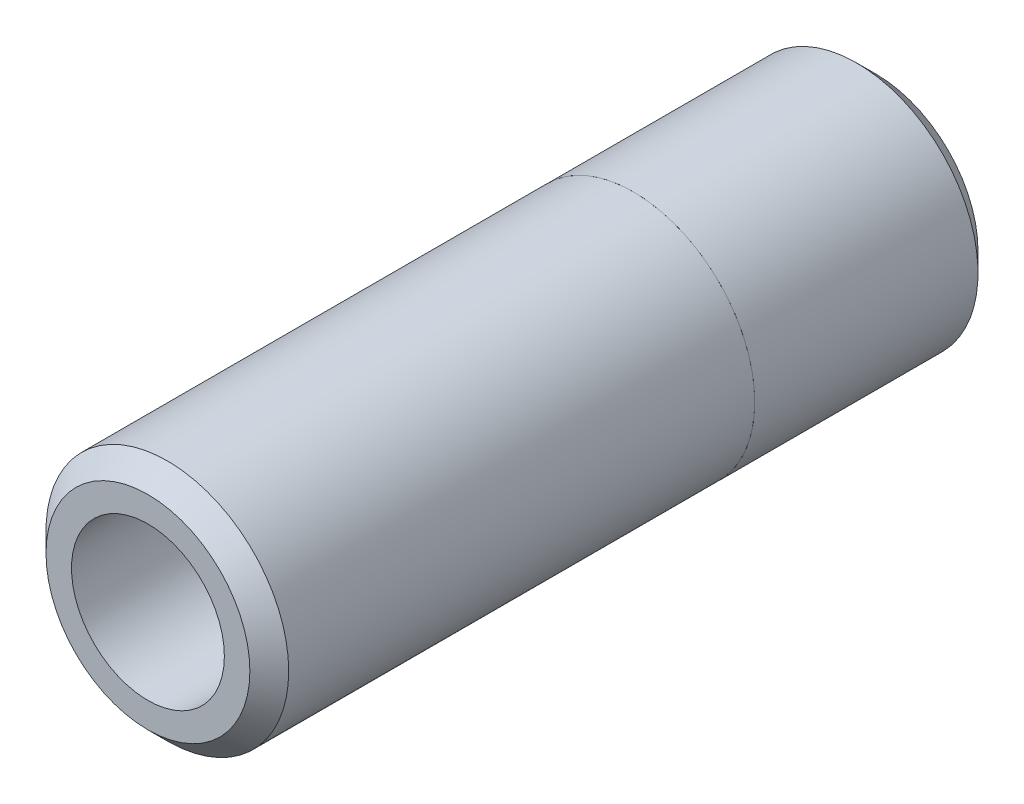
from build123d import *

# Parameters (mm, degrees)
SKETCH1_R               = 4.7625
SIDE_WITH_HOLE_DEPTH    = 19.05
SKETCH2_R               = 4.7625
SIDE_WITHOUT_HOLE_DEPTH = 9.525
CHAMFER1_SIZE           = 0.762
CHAMFER2_SIZE           = 0.762


with BuildPart() as part:
    # Sketch1 → Side With Hole (new body)
    with BuildSketch(Plane.XY):
        Circle(SKETCH1_R)
    extrude(amount=SIDE_WITH_HOLE_DEPTH)


with BuildPart() as body_2:
    # Sketch2 → Side Without Hole (new body)
    with BuildSketch(Plane(origin=(0, 0, 0), x_dir=(-1, 0, 0), z_dir=(0, 0, -1))):
        Circle(SKETCH2_R)
    extrude(amount=SIDE_WITHOUT_HOLE_DEPTH)


with BuildPart() as f_6_0_6_diameter_hole1_tool:
    # Sketch4 → Ø6.0 (6) Diameter Hole1 (revolve)
    with BuildSketch(Plane(origin=(0, 0, 19.05), x_dir=(0, -1, 0), z_dir=(1, 0, 0))):
        Polygon((0, 0), (0, 22.757581857), (3, 20.955), (3, 0), align=None)
    revolve(axis=Axis((0, 0, 25.4), (0, 0, -1)))


with BuildPart() as part_1:
    add(part.part)

    # Ø6.0 (6) Diameter Hole1: cut by f_6_0_6_diameter_hole1_tool
    add(f_6_0_6_diameter_hole1_tool.part, mode=Mode.SUBTRACT)

    # Chamfer2
    chamfer2_edges = [part_1.edges().sort_by_distance(p)[0] for p in [
        (-4.7625, 0, 19.05),
    ]]
    chamfer(chamfer2_edges, length=CHAMFER2_SIZE)


with BuildPart() as body_2_1:
    add(body_2.part)

    # Ø6.0 (6) Diameter Hole1: cut by f_6_0_6_diameter_hole1_tool
    add(f_6_0_6_diameter_hole1_tool.part, mode=Mode.SUBTRACT)

    # Chamfer1
    chamfer1_edges = [body_2_1.edges().sort_by_distance(p)[0] for p in [
        (4.7625, 0, -9.525),
    ]]
    chamfer(chamfer1_edges, length=CHAMFER1_SIZE)


solid = Compound([part_1.part, body_2_1.part])
